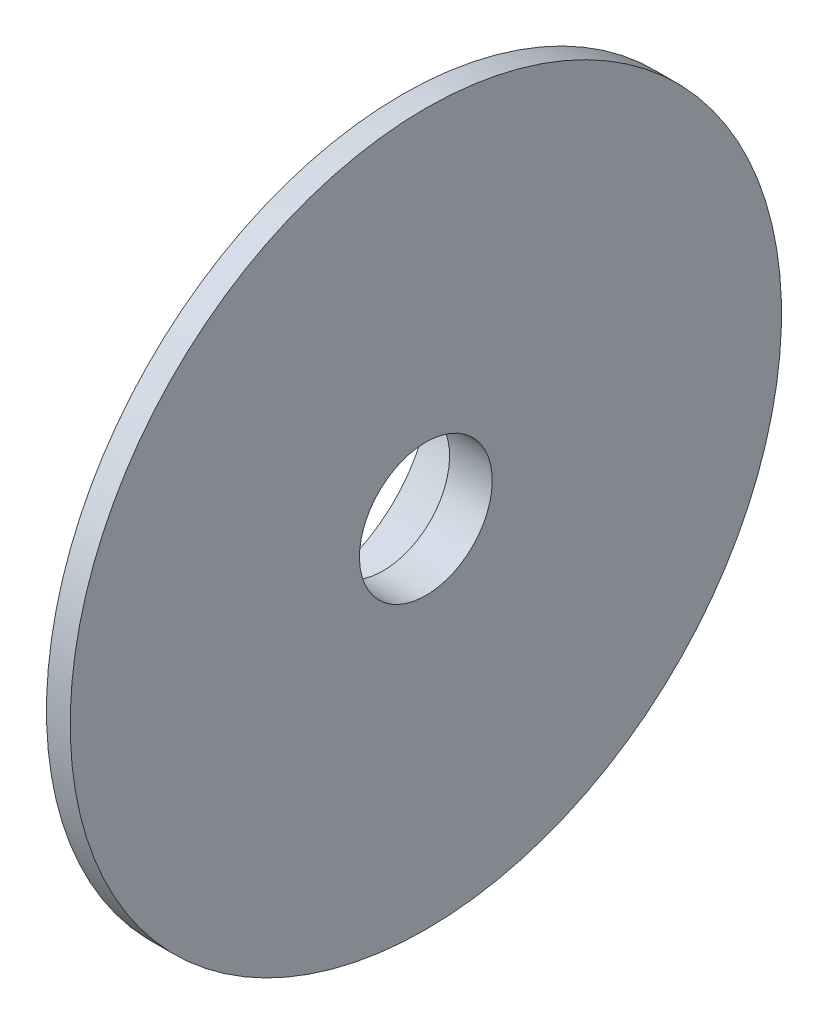
from build123d import *


with BuildPart() as part:
    # Sketch1 → Base-Revolve (revolve)
    with BuildSketch(Plane.XY):
        Polygon((0, 37.5), (0, 7), (-4.5, 7), (-4.5, 9), (-2, 9), (-2, 11.5), (-5, 11.5), (-5, 13), (-12.5, 13), (-12.5, 15), (-8.5, 15), (-8.5, 14.35), (-7.5, 14.35), (-7.5, 15), (-2.5, 15), (-2.5, 25), (-6, 25), (-6, 27), (-2.5, 27), (-2.5, 37.5), align=None)
    revolve(axis=Axis((0, 0, 0), (-1, 0, 0)))


solid = part.part
